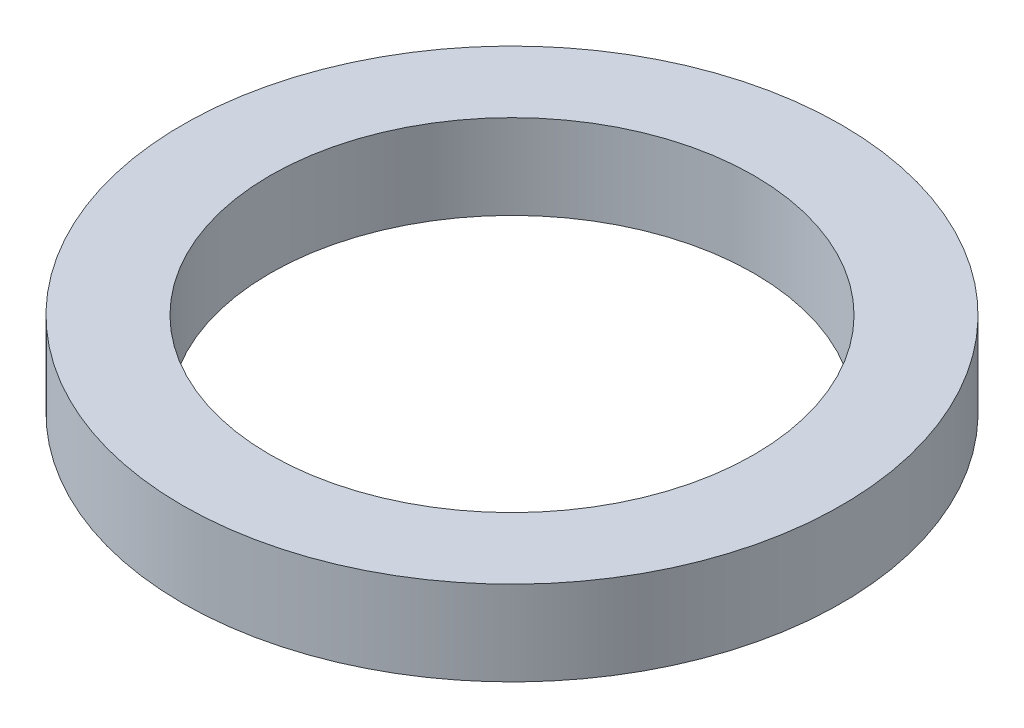
from build123d import *

# Parameters (mm, degrees)
SKETCH1_R           = 10.9
SKETCH1_R_2         = 8
BOSS_EXTRUDE1_DEPTH = 2.8


with BuildPart() as part:
    # Sketch1 → Boss-Extrude1 (new body)
    with BuildSketch(Plane(origin=(0, 0, 0), x_dir=(1, 0, 0), z_dir=(0, 1, 0))):
        Circle(SKETCH1_R)
        Circle(SKETCH1_R_2, mode=Mode.SUBTRACT)
    extrude(amount=BOSS_EXTRUDE1_DEPTH)


solid = part.part
